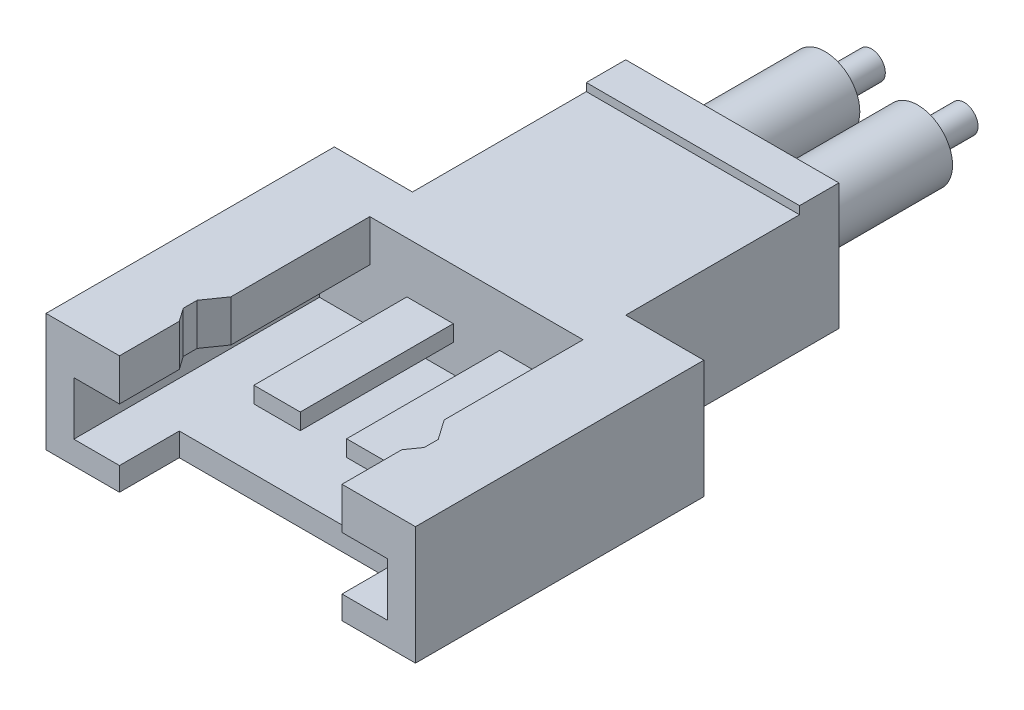
from build123d import *

# Parameters (mm, degrees)
SKETCH1_W           = 4.6
SKETCH1_H           = 2.55
BOSS_EXTRUDE1_DEPTH = 4.6
SKETCH2_W           = 7.97
SKETCH2_H           = 2.55
BOSS_EXTRUDE2_DEPTH = 6.22
SKETCH3_W           = 4.6
SKETCH3_H           = 0.85
BOSS_EXTRUDE3_DEPTH = 0.17
SKETCH4_W           = 4.8
SKETCH4_H           = 2.55
CUT_EXTRUDE1_DEPTH  = 1.29
SKETCH5_W           = 6.77
SKETCH5_H           = 1.15
CUT_EXTRUDE2_DEPTH  = 5.3
CUT_EXTRUDE3_REACH  = 4.55
SKETCH7_W           = 1
SKETCH7_H           = 0.35
BOSS_EXTRUDE4_DEPTH = 3.3
SKETCH8_R           = 0.75
BOSS_EXTRUDE5_DEPTH = 3
SKETCH9_R           = 0.3
BOSS_EXTRUDE6_DEPTH = 1


with BuildPart() as part:
    # Sketch1 → Boss-Extrude1 (new body)
    with BuildSketch(Plane.XY):
        Rectangle(SKETCH1_W, SKETCH1_H)
    extrude(amount=BOSS_EXTRUDE1_DEPTH)

    # Sketch2 → Boss-Extrude2 (add)
    with BuildSketch(Plane.XY.offset(4.6)):
        Rectangle(SKETCH2_W, SKETCH2_H)
    extrude(amount=BOSS_EXTRUDE2_DEPTH)

    # Sketch3 → Boss-Extrude3 (add)
    with BuildSketch(Plane(origin=(0, 1.275, 0), x_dir=(1, 0, 0), z_dir=(0, 1, 0))):
        with Locations((0, -0.425)):
            Rectangle(SKETCH3_W, SKETCH3_H)
    extrude(amount=BOSS_EXTRUDE3_DEPTH)

    # Sketch4 → Cut-Extrude1 (cut)
    with BuildSketch(Plane.XY.offset(10.82)):
        Rectangle(SKETCH4_W, SKETCH4_H)
    extrude(amount=-CUT_EXTRUDE1_DEPTH, mode=Mode.SUBTRACT)

    # Sketch5 → Cut-Extrude2 (cut)
    with BuildSketch(Plane.XY.offset(10.82)):
        with Locations((0, -0.2)):
            Rectangle(SKETCH5_W, SKETCH5_H)
    extrude(amount=-CUT_EXTRUDE2_DEPTH, mode=Mode.SUBTRACT)

    # Sketch6 → Cut-Extrude3 (cut, up to next)
    with BuildSketch(Plane(origin=(0, 1.275, 0), x_dir=(1, 0, 0), z_dir=(0, 1, 0)), mode=Mode.PRIVATE) as cut_extrude3_sk1:
        Polygon((2.3, -8.515925997), (2.3, -5.52), (-2.3, -5.52), (-2.3, -8.515925997), (-2.3, -9.53), (2.3, -9.53), align=None)
    cut_extrude3_tool1 = extrude(cut_extrude3_sk1.sketch, amount=-CUT_EXTRUDE3_REACH, mode=Mode.PRIVATE) & part.part
    add(cut_extrude3_tool1.solids().sort_by_distance((0, 1.275, 7.525))[0], mode=Mode.SUBTRACT)
    # Sketch6 → Cut-Extrude3 (cut, up to next)
    with BuildSketch(Plane(origin=(0, 1.275, 0), x_dir=(1, 0, 0), z_dir=(0, 1, 0)), mode=Mode.PRIVATE) as cut_extrude3_sk2:
        Polygon((-2.3, -9.53), (-2.3, -8.515925997), (-2.6, -8.944370399), (-2.6, -9.244370399), (-2.4, -9.53), align=None)
    cut_extrude3_tool2 = extrude(cut_extrude3_sk2.sketch, amount=-CUT_EXTRUDE3_REACH, mode=Mode.PRIVATE) & part.part
    add(cut_extrude3_tool2.solids().sort_by_distance((-2.423539, 1.275, 9.078047))[0], mode=Mode.SUBTRACT)
    # Sketch6 → Cut-Extrude3 (cut, up to next)
    with BuildSketch(Plane(origin=(0, 1.275, 0), x_dir=(1, 0, 0), z_dir=(0, 1, 0)), mode=Mode.PRIVATE) as cut_extrude3_sk3:
        Polygon((2.6, -8.944370399), (2.3, -8.515925997), (2.3, -9.53), (2.4, -9.53), (2.6, -9.244370399), align=None)
    cut_extrude3_tool3 = extrude(cut_extrude3_sk3.sketch, amount=-CUT_EXTRUDE3_REACH, mode=Mode.PRIVATE) & part.part
    add(cut_extrude3_tool3.solids().sort_by_distance((2.423539, 1.275, 9.078047))[0], mode=Mode.SUBTRACT)

    # Sketch7 → Boss-Extrude4 (add)
    with BuildSketch(Plane.XY.offset(5.52)):
        with Locations((1, 0)):
            Rectangle(SKETCH7_W, SKETCH7_H)
        with Locations((-1, 0)):
            Rectangle(SKETCH7_W, SKETCH7_H)
    extrude(amount=BOSS_EXTRUDE4_DEPTH)

    # Sketch8 → Boss-Extrude5 (add)
    with BuildSketch(Plane(origin=(0, 0, 0), x_dir=(-1, 0, 0), z_dir=(0, 0, -1))):
        with Locations((-1, 0)):
            Circle(SKETCH8_R)
        with Locations((1, 0)):
            Circle(SKETCH8_R)
    extrude(amount=BOSS_EXTRUDE5_DEPTH)

    # Sketch9 → Boss-Extrude6 (add)
    with BuildSketch(Plane(origin=(0, 0, -3), x_dir=(-1, 0, 0), z_dir=(0, 0, -1))):
        with Locations((-1, 0)):
            Circle(SKETCH9_R)
        with Locations((1, 0)):
            Circle(SKETCH9_R)
    extrude(amount=BOSS_EXTRUDE6_DEPTH)


solid = part.part
